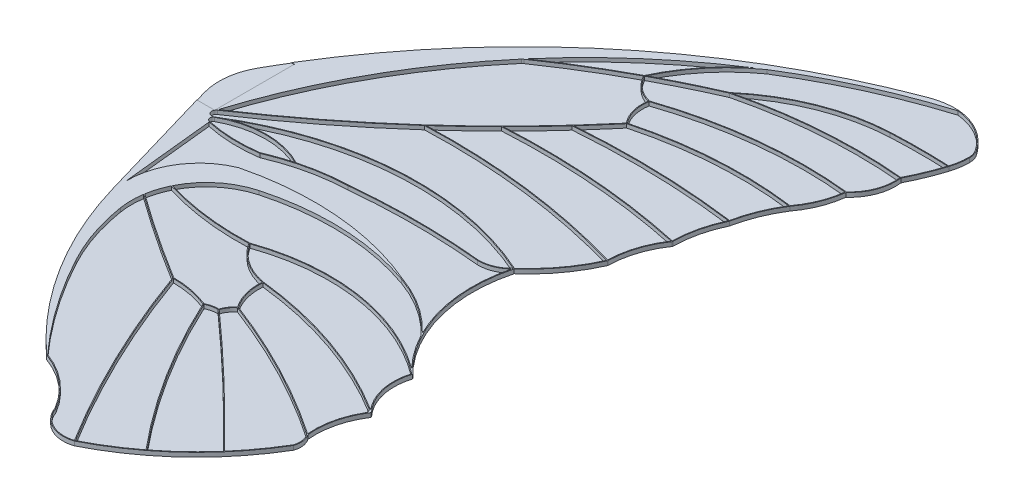
from build123d import *

# Parameters (mm, degrees)
RESSALTO_EXTRUS_O1_DEPTH = 2
RESSALTO_EXTRUS_O2_START = -0.2
RESSALTO_EXTRUS_O2_DEPTH = 0.2
ESBO_O3_W                = 13.5
ESBO_O3_H                = 41.75
CORTE_EXTRUS_O2_DEPTH    = 0.2


with BuildPart() as part:
    # Esboço1 → Ressalto-extrusão1 (new body)
    with BuildSketch(Plane(origin=(0, 0, 0), x_dir=(1, 0, 0), z_dir=(0, 1, 0))):
        with BuildLine():
            Line((-2.891885916, -25.331386579), (16.890636414, -92.871950666))
            ThreePointArc((16.890636414, -92.871950666), (39.509715195, -143.24681252), (74.924632392, -185.614643143))
            ThreePointArc((74.924632392, -185.614643143), (90.053250325, -194.317508541), (101.317198447, -207.649365854))
            ThreePointArc((101.317198447, -207.649365854), (109.339932134, -216.703217601), (121.414649078, -217.436496537))
            ThreePointArc((121.414649078, -217.436496537), (121.423131136, -217.432766567), (121.431473842, -217.428734539))
            ThreePointArc((121.431473842, -217.428734539), (155.03526296, -193.949101447), (180.732122887, -162.008857192))
            ThreePointArc((180.732122887, -162.008857192), (181.188239019, -157.584851871), (179.579203123, -153.438664648))
            ThreePointArc((179.579203123, -153.438664648), (180.544757753, -139.671656891), (186.018022228, -127.002553753))
            ThreePointArc((186.018022228, -127.002553753), (186.089619632, -126.716123165), (185.969624565, -126.446364285))
            ThreePointArc((185.969624565, -126.446364285), (179.033051629, -113.383903181), (179.566523634, -98.60353303))
            ThreePointArc((179.566523634, -98.60353303), (179.568845143, -98.494180052), (179.513294894, -98.399958861))
            ThreePointArc((179.513294894, -98.399958861), (158.838253644, -64.171647637), (158.407910237, -24.186032419))
            ThreePointArc((158.407910237, -24.186032419), (170.345122282, -11.218617872), (179.220005433, 4.009229005))
            ThreePointArc((179.220005433, 4.009229005), (179.232638679, 4.047550287), (179.237322945, 4.087627428))
            ThreePointArc((179.237322945, 4.087627428), (181.421355488, 17.384501121), (187.376766076, 29.472095295))
            ThreePointArc((187.376766076, 29.472095295), (187.463240561, 29.647364474), (187.495240153, 29.840167866))
            ThreePointArc((187.495240153, 29.840167866), (189.041723719, 42.177149), (193.176832614, 53.902915046))
            ThreePointArc((193.176832614, 53.902915046), (193.186037336, 53.925638832), (193.192392505, 53.949318131))
            ThreePointArc((193.192392505, 53.949318131), (196.683977717, 65.597702677), (202.212176332, 76.428909901))
            ThreePointArc((202.212176332, 76.428909901), (207.81407221, 86.384811826), (210.665701384, 97.446883587))
            ThreePointArc((210.665701384, 97.446883587), (217.157138995, 106.918422119), (218.517613108, 118.320084919))
            ThreePointArc((218.517613108, 118.320084919), (222.53357195, 127.064851642), (225.828988219, 136.105819626))
            ThreePointArc((225.828988219, 136.105819626), (226.936116515, 140.796582456), (227.308114084, 145.601851107))
            ThreePointArc((227.308114084, 145.601851107), (226.92415432, 148.202079294), (225.805048795, 150.58035904))
            ThreePointArc((225.805048795, 150.58035904), (216.132997815, 159.854580332), (203.432149719, 164.126372503))
            ThreePointArc((203.432149719, 164.126372503), (196.305976757, 163.870755082), (189.397159866, 162.105555232))
            ThreePointArc((189.397159866, 162.105555232), (80.341988523, 97.826401656), (0, 0))
            ThreePointArc((0, 0), (-4.004170085, -12.373640544), (-2.891885916, -25.331386579))
        make_face()
        with BuildLine():
            ThreePointArc((75.061191815, -185.238675693), (55.710509097, -160.996401051), (39.414410112, -134.60371344))
            ThreePointArc((39.414410112, -134.60371344), (32.024240404, -117.575549791), (27.564899418, -99.556469804))
            ThreePointArc((27.564899418, -99.556469804), (27.068868432, -93.446906914), (27.530070276, -87.334616156))
            ThreePointArc((27.530070276, -87.334616156), (50.023709071, -102.94081443), (73.078069491, -117.706100627))
            ThreePointArc((73.078069491, -117.706100627), (94.455943613, -168.678582058), (121.038273811, -217.140805352))
            ThreePointArc((121.038273811, -217.140805352), (109.381253065, -216.277627559), (101.682640282, -207.482028103))
            ThreePointArc((101.682640282, -207.482028103), (90.32477142, -194.023121535), (75.061191815, -185.238675693))
        make_face(mode=Mode.SUBTRACT)
        with BuildLine():
            ThreePointArc((144.073565841, -202.71747677), (133.074913856, -210.37840662), (121.414649077, -216.988884436))
            ThreePointArc((121.414649077, -216.988884436), (94.877808499, -168.632444086), (73.527113878, -117.772862193))
            ThreePointArc((73.527113878, -117.772862193), (83.369797481, -118.753083082), (92.849554804, -121.576813702))
            ThreePointArc((92.849554804, -121.576813702), (115.816888065, -163.816723913), (144.073565841, -202.71747677))
        make_face(mode=Mode.SUBTRACT)
        with BuildLine():
            ThreePointArc((11.879579324, -37.059994062), (10.253925603, -35.789100329), (11.070359275, -33.894012744))
            ThreePointArc((11.070359275, -33.894012744), (31.766860679, -28.367665282), (52.618625636, -33.275779462))
            ThreePointArc((52.618625636, -33.275779462), (45.854920305, -35.402452346), (39.251467246, -37.984090401))
            ThreePointArc((39.251467246, -37.984090401), (25.524465377, -38.738184329), (11.879579324, -37.059994062))
        make_face(mode=Mode.SUBTRACT)
        with BuildLine():
            ThreePointArc((30.954862617, -76.306512457), (53.928434843, -81.142970387), (77.385630644, -82.110602151))
            ThreePointArc((77.385630644, -82.110602151), (86.442113829, -91.376407189), (98.476067628, -96.178384559))
            ThreePointArc((98.476067628, -96.178384559), (99.325868559, -105.523547237), (103.329588684, -114.010269354))
            ThreePointArc((103.329588684, -114.010269354), (100.839320134, -116.575545142), (99.274681475, -119.790196472))
            ThreePointArc((99.274681475, -119.790196472), (96.035057019, -120.070400422), (92.986045613, -121.200537717))
            ThreePointArc((92.986045613, -121.200537717), (83.327149533, -118.337154453), (73.29906303, -117.372417034))
            ThreePointArc((73.29906303, -117.372417034), (50.20912985, -102.583681626), (27.682018255, -86.950993041))
            ThreePointArc((27.682018255, -86.950993041), (27.640126359, -86.915622588), (27.604076284, -86.874314091))
            ThreePointArc((27.604076284, -86.874314091), (28.904488661, -81.471516217), (30.954862617, -76.306512457))
        make_face(mode=Mode.SUBTRACT)
        with BuildLine():
            Line((16.890636414, -86.132821), (11.85931196, -37.464698075))
            ThreePointArc((11.85931196, -37.464698075), (25.569939965, -39.139925167), (39.361189646, -38.372371707))
            ThreePointArc((39.361189646, -38.372371707), (57.801285112, -32.389959226), (77.032122973, -29.940213308))
            ThreePointArc((77.032122973, -29.940213308), (111.045550918, -28.261906009), (145.058243072, -29.955059416))
            ThreePointArc((145.058243072, -29.955059416), (151.973262614, -28.636570967), (157.848232778, -24.758345519))
            ThreePointArc((157.848232778, -24.758345519), (155.983137797, -51.598831019), (163.541497745, -77.420555131))
            ThreePointArc((163.541497745, -77.420555131), (149.854946418, -65.924493525), (133.842737694, -57.981553802))
            ThreePointArc((133.842737694, -57.981553802), (87.670250354, -46.538605901), (40.261886529, -50.448424731))
            ThreePointArc((40.261886529, -50.448424731), (23.057242833, -64.675979535), (16.890636414, -86.132821))
        make_face(mode=Mode.SUBTRACT)
        with BuildLine():
            ThreePointArc((31.132626071, -75.942156085), (41.348809985, -63.051320172), (55.949990062, -55.478367997))
            ThreePointArc((55.949990062, -55.478367997), (95.05027781, -50.955008797), (133.708809753, -58.358466666))
            ThreePointArc((133.708809753, -58.358466666), (149.927402921, -66.450957854), (163.72457307, -78.205500545))
            ThreePointArc((163.72457307, -78.205500545), (163.984765643, -78.494020984), (164.23916715, -78.787660375))
            ThreePointArc((164.23916715, -78.787660375), (169.918511042, -87.993064481), (176.841349297, -96.30382391))
            ThreePointArc((176.841349297, -96.30382391), (128.956486326, -76.690746726), (77.454382768, -81.707341939))
            ThreePointArc((77.454382768, -81.707341939), (54.053212131, -80.755434548), (31.132626071, -75.942156085))
        make_face(mode=Mode.SUBTRACT)
        with BuildLine():
            ThreePointArc((144.390735312, -202.473293628), (116.188479484, -163.656017033), (93.258837749, -121.508897014))
            ThreePointArc((93.258837749, -121.508897014), (96.210985678, -120.441238679), (99.340524238, -120.194135217))
            ThreePointArc((99.340524238, -120.194135217), (132.717797326, -151.058354618), (164.973783051, -183.092614136))
            ThreePointArc((164.973783051, -183.092614136), (155.156655203, -193.286781209), (144.390735312, -202.473293628))
        make_face(mode=Mode.SUBTRACT)
        with BuildLine():
            ThreePointArc((165.237327428, -182.789851396), (133.00300151, -150.777649689), (99.649253017, -119.933520799))
            ThreePointArc((99.649253017, -119.933520799), (101.18300434, -116.782199542), (103.6372122, -114.280183841))
            ThreePointArc((103.6372122, -114.280183841), (142.598272069, -131.743297777), (179.242488543, -153.655073914))
            ThreePointArc((179.242488543, -153.655073914), (180.78822356, -157.611813736), (180.367828424, -161.838911403))
            ThreePointArc((180.367828424, -161.838911403), (173.27117969, -172.652799603), (165.237327428, -182.789851396))
        make_face(mode=Mode.SUBTRACT)
        with BuildLine():
            ThreePointArc((179.145908385, -153.10569005), (142.589295312, -131.287701646), (103.734386544, -113.889234988))
            ThreePointArc((103.734386544, -113.889234988), (99.732427529, -105.493744387), (98.872883702, -96.233014243))
            ThreePointArc((98.872883702, -96.233014243), (143.098520561, -106.179072223), (183.998274189, -125.724945907))
            ThreePointArc((183.998274189, -125.724945907), (184.88113455, -126.943403006), (184.664770288, -128.432451905))
            ThreePointArc((184.664770288, -128.432451905), (179.978340813, -140.338043697), (179.145908385, -153.10569005))
        make_face(mode=Mode.SUBTRACT)
        with BuildLine():
            ThreePointArc((98.718726209, -95.813871314), (86.794460768, -91.13013492), (77.796430253, -82.0108729))
            ThreePointArc((77.796430253, -82.0108729), (130.390825581, -77.316445759), (178.842177575, -98.308695665))
            ThreePointArc((178.842177575, -98.308695665), (179.042636723, -98.592893915), (179.048514046, -98.940626531))
            ThreePointArc((179.048514046, -98.940626531), (178.557910182, -113.090704042), (184.838939896, -125.779835275))
            ThreePointArc((184.838939896, -125.779835275), (143.48611956, -105.890223927), (98.718726209, -95.813871314))
        make_face(mode=Mode.SUBTRACT)
        with BuildLine():
            ThreePointArc((77.00571445, -29.540870677), (64.991382888, -30.640116345), (53.184593307, -33.120484))
            ThreePointArc((53.184593307, -33.120484), (34.997673911, -28.037667048), (16.344111956, -30.977682642))
            ThreePointArc((16.344111956, -30.977682642), (86.294442644, -10.497166778), (157.8926845, -24.142387796))
            ThreePointArc((157.8926845, -24.142387796), (152.04587989, -28.173512381), (145.079823263, -29.555230382))
            ThreePointArc((145.079823263, -29.555230382), (111.043124536, -27.861905479), (77.00571445, -29.540870677))
        make_face(mode=Mode.SUBTRACT)
        with BuildLine():
            ThreePointArc((10.884162093, -33.792177396), (7.936541731, -32.891512454), (8.646375466, -29.892212669))
            ThreePointArc((8.646375466, -29.892212669), (40.102456108, -7.368908744), (69.841232126, 17.377594644))
            ThreePointArc((69.841232126, 17.377594644), (124.842337918, 15.064533704), (178.761046703, 3.962969299))
            ThreePointArc((178.761046703, 3.962969299), (169.975242199, -11.046105684), (158.195344978, -23.840507352))
            ThreePointArc((158.195344978, -23.840507352), (83.286903321, -10.270827271), (10.884162093, -33.792177396))
        make_face(mode=Mode.SUBTRACT)
        with BuildLine():
            ThreePointArc((65.163327011, 72.986151676), (65.512554625, 73.261919505), (65.873725431, 73.521849244))
            ThreePointArc((65.873725431, 73.521849244), (85.034977645, 85.921559119), (104.841521177, 97.262071658))
            ThreePointArc((104.841521177, 97.262071658), (110.028306452, 90.798172973), (117.42803317, 87.066045938))
            ThreePointArc((117.42803317, 87.066045938), (117.855262612, 78.759779692), (121.642967981, 71.355060116))
            ThreePointArc((121.642967981, 71.355060116), (68.727790014, 16.919047723), (8.608266137, -29.43759531))
            ThreePointArc((8.608266137, -29.43759531), (31.751463387, 24.609289931), (65.163327011, 72.986151676))
        make_face(mode=Mode.SUBTRACT)
        with BuildLine():
            ThreePointArc((130.105906511, 129.878932118), (115.574418721, 115.248461285), (104.7762631, 97.681029789))
            ThreePointArc((104.7762631, 97.681029789), (85.206415837, 86.494114614), (66.264337516, 74.274308482))
            ThreePointArc((66.264337516, 74.274308482), (96.177838084, 104.381251589), (130.105906511, 129.878932118))
        make_face(mode=Mode.SUBTRACT)
        with BuildLine():
            ThreePointArc((178.842127699, 4.355978275), (125.114397795, 15.433974602), (70.307334653, 17.795498029))
            ThreePointArc((70.307334653, 17.795498029), (80.610470403, 27.291705844), (90.660333167, 37.055558956))
            ThreePointArc((90.660333167, 37.055558956), (139.066008112, 36.613044124), (186.958653653, 29.570339432))
            ThreePointArc((186.958653653, 29.570339432), (181.056540683, 17.556695855), (178.842127699, 4.355978275))
        make_face(mode=Mode.SUBTRACT)
        with BuildLine():
            ThreePointArc((192.697680535, 53.826703734), (188.632596088, 42.184795574), (187.097186474, 29.949540999))
            ThreePointArc((187.097186474, 29.949540999), (139.348979985, 36.992165146), (91.086670247, 37.481283297))
            ThreePointArc((91.086670247, 37.481283297), (100.008574142, 46.616810225), (108.708987791, 55.963522143))
            ThreePointArc((108.708987791, 55.963522143), (150.759305033, 57.095075342), (192.697680535, 53.826703734))
        make_face(mode=Mode.SUBTRACT)
        with BuildLine():
            ThreePointArc((122.015582584, 71.176571043), (161.60786351, 77.700482874), (201.712469543, 76.384918569))
            ThreePointArc((201.712469543, 76.384918569), (196.290949467, 65.692265225), (192.837884131, 54.211757605))
            ThreePointArc((192.837884131, 54.211757605), (151.026567478, 57.488322955), (109.101297358, 56.395708613))
            ThreePointArc((109.101297358, 56.395708613), (115.62650859, 63.726667144), (122.015582584, 71.176571043))
        make_face(mode=Mode.SUBTRACT)
        with BuildLine():
            ThreePointArc((201.957251989, 76.756062495), (161.711502037, 78.108067884), (121.975723187, 71.579960434))
            ThreePointArc((121.975723187, 71.579960434), (118.238216137, 78.876060323), (117.832890254, 87.063718319))
            ThreePointArc((117.832890254, 87.063718319), (163.48468813, 97.222424933), (210.25288905, 97.368547957))
            ThreePointArc((210.25288905, 97.368547957), (207.439428108, 86.525283804), (201.957251989, 76.756062495))
        make_face(mode=Mode.SUBTRACT)
        with BuildLine():
            ThreePointArc((105.194171334, 97.451237144), (119.956691333, 104.989862866), (135.00518658, 111.940090583))
            ThreePointArc((135.00518658, 111.940090583), (176.305917901, 118.563594016), (218.132560685, 118.172238852))
            ThreePointArc((218.132560685, 118.172238852), (216.767534509, 107.01891476), (210.409374715, 97.754264805))
            ThreePointArc((210.409374715, 97.754264805), (163.467402557, 97.622974649), (117.64681506, 87.422986968))
            ThreePointArc((117.64681506, 87.422986968), (110.323017386, 91.074314456), (105.194171334, 97.451237144))
        make_face(mode=Mode.SUBTRACT)
        with BuildLine():
            ThreePointArc((134.231187047, 132.489001443), (167.471686306, 150.296359156), (202.714101827, 163.712950676))
            ThreePointArc((202.714101827, 163.712950676), (203.051769924, 163.742347016), (203.390434406, 163.728553659))
            ThreePointArc((203.390434406, 163.728553659), (215.925826131, 159.51241094), (225.471877456, 150.359006698))
            ThreePointArc((225.471877456, 150.359006698), (226.541225779, 148.086469034), (226.908114084, 145.601851107))
            ThreePointArc((226.908114084, 145.601851107), (226.552562533, 140.93374904), (225.494110918, 136.373346207))
            ThreePointArc((225.494110918, 136.373346207), (210.329945011, 136.70097858), (195.166849247, 136.327083543))
            ThreePointArc((195.166849247, 136.327083543), (162.992204891, 129.355762587), (134.832810466, 112.301274588))
            ThreePointArc((134.832810466, 112.301274588), (119.960236596, 105.436275442), (105.366397335, 97.997087152))
            ThreePointArc((105.366397335, 97.997087152), (117.587042911, 117.093961509), (134.231187047, 132.489001443))
        make_face(mode=Mode.SUBTRACT)
        with BuildLine():
            ThreePointArc((218.195023717, 118.568133932), (176.701785201, 118.994028297), (135.713472408, 112.526537053))
            ThreePointArc((135.713472408, 112.526537053), (163.518917342, 129.134060421), (195.18595438, 135.927540062))
            ThreePointArc((195.18595438, 135.927540062), (210.276471462, 136.300892078), (225.368164637, 135.97856519))
            ThreePointArc((225.368164637, 135.97856519), (222.128079781, 127.130596632), (218.195023717, 118.568133932))
        make_face(mode=Mode.SUBTRACT)
    extrude(amount=RESSALTO_EXTRUS_O1_DEPTH)

    # Esboço1<3> → Ressalto-extrusão2 (add)
    with BuildSketch(Plane(origin=(0, 0, 0), x_dir=(1, 0, 0), z_dir=(0, 1, 0)).offset(RESSALTO_EXTRUS_O2_START)):
        with BuildLine():
            Line((-2.891885916, -25.331386579), (16.890636414, -92.871950666))
            ThreePointArc((16.890636414, -92.871950666), (39.509715195, -143.24681252), (74.924632392, -185.614643143))
            ThreePointArc((74.924632392, -185.614643143), (90.053250325, -194.317508541), (101.317198447, -207.649365854))
            ThreePointArc((101.317198447, -207.649365854), (109.339932134, -216.703217601), (121.414649078, -217.436496537))
            ThreePointArc((121.414649078, -217.436496537), (121.423131136, -217.432766567), (121.431473842, -217.428734539))
            ThreePointArc((121.431473842, -217.428734539), (155.03526296, -193.949101447), (180.732122887, -162.008857192))
            ThreePointArc((180.732122887, -162.008857192), (181.188239019, -157.584851871), (179.579203123, -153.438664648))
            ThreePointArc((179.579203123, -153.438664648), (180.544757753, -139.671656891), (186.018022228, -127.002553753))
            ThreePointArc((186.018022228, -127.002553753), (186.089619632, -126.716123165), (185.969624565, -126.446364285))
            ThreePointArc((185.969624565, -126.446364285), (179.033051629, -113.383903181), (179.566523634, -98.60353303))
            ThreePointArc((179.566523634, -98.60353303), (179.568845143, -98.494180052), (179.513294894, -98.399958861))
            ThreePointArc((179.513294894, -98.399958861), (158.838253644, -64.171647637), (158.407910237, -24.186032419))
            ThreePointArc((158.407910237, -24.186032419), (170.345122282, -11.218617872), (179.220005433, 4.009229005))
            ThreePointArc((179.220005433, 4.009229005), (179.232638679, 4.047550287), (179.237322945, 4.087627428))
            ThreePointArc((179.237322945, 4.087627428), (181.421355488, 17.384501121), (187.376766076, 29.472095295))
            ThreePointArc((187.376766076, 29.472095295), (187.463240561, 29.647364474), (187.495240153, 29.840167866))
            ThreePointArc((187.495240153, 29.840167866), (189.041723719, 42.177149), (193.176832614, 53.902915046))
            ThreePointArc((193.176832614, 53.902915046), (193.186037336, 53.925638832), (193.192392505, 53.949318131))
            ThreePointArc((193.192392505, 53.949318131), (196.683977717, 65.597702677), (202.212176332, 76.428909901))
            ThreePointArc((202.212176332, 76.428909901), (207.81407221, 86.384811826), (210.665701384, 97.446883587))
            ThreePointArc((210.665701384, 97.446883587), (217.157138995, 106.918422119), (218.517613108, 118.320084919))
            ThreePointArc((218.517613108, 118.320084919), (222.53357195, 127.064851642), (225.828988219, 136.105819626))
            ThreePointArc((225.828988219, 136.105819626), (226.936116515, 140.796582456), (227.308114084, 145.601851107))
            ThreePointArc((227.308114084, 145.601851107), (226.92415432, 148.202079294), (225.805048795, 150.58035904))
            ThreePointArc((225.805048795, 150.58035904), (216.132997815, 159.854580332), (203.432149719, 164.126372503))
            ThreePointArc((203.432149719, 164.126372503), (196.305976757, 163.870755082), (189.397159866, 162.105555232))
            ThreePointArc((189.397159866, 162.105555232), (80.341988523, 97.826401656), (0, 0))
            ThreePointArc((0, 0), (-4.004170085, -12.373640544), (-2.891885916, -25.331386579))
        make_face()
    extrude(amount=RESSALTO_EXTRUS_O2_DEPTH)

    # Esboço3 → Corte-extrusão2 (cut)
    with BuildSketch(Plane(origin=(0, 2, 0), x_dir=(1, 0, 0), z_dir=(0, 1, 0))):
        with Locations((1.25, -9.755)):
            Rectangle(ESBO_O3_W, ESBO_O3_H)
    extrude(amount=-CORTE_EXTRUS_O2_DEPTH, mode=Mode.SUBTRACT)


solid = part.part
